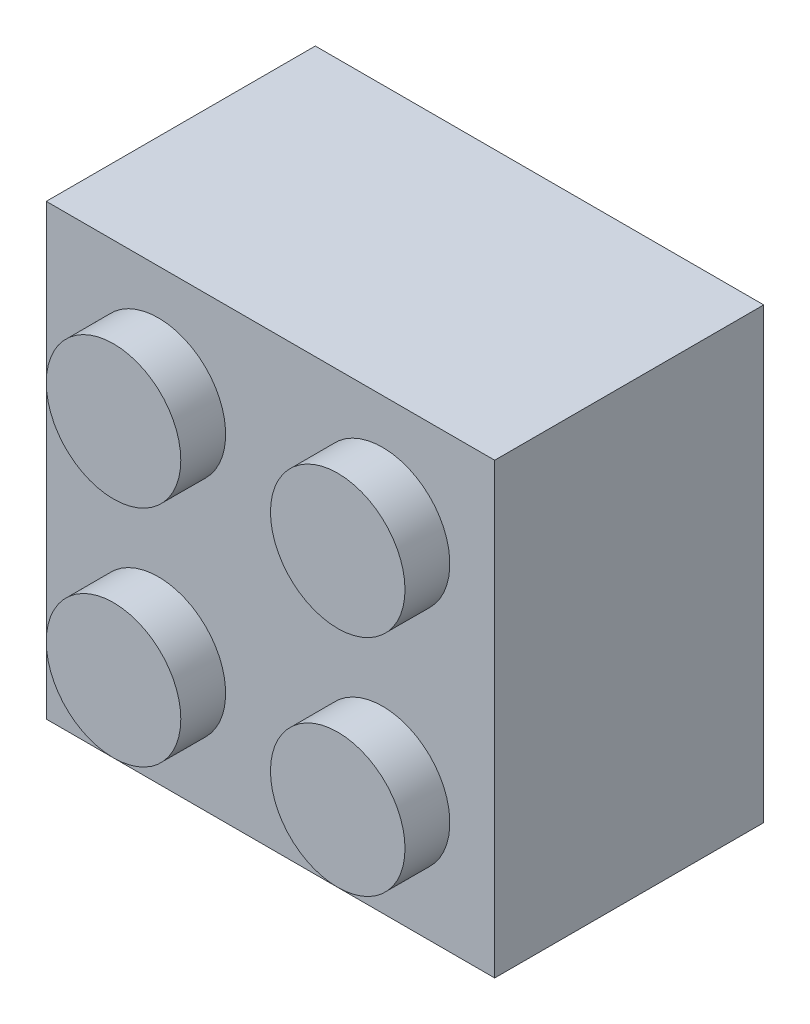
from build123d import *

# Parameters (mm, degrees)
SKETCH1_W            = 15.875
SKETCH1_H            = 15.875
BOSS_EXTRUDE1_DEPTH  = 9.525
SKETCH2_R            = 2.38125
BOSS_EXTRUDE2_DEPTH  = 1.5875
LPATTERN1_COUNT      = 2
LPATTERN1_PITCH      = 7.9375
LPATTERN1_COUNT_DIR2 = 2
LPATTERN1_PITCH_DIR2 = 7.9375
SHELL1_T             = -1.5875
SKETCH3_R            = 3.175
SKETCH3_R_2          = 2.38125
BOSS_EXTRUDE9_DEPTH  = 7.9375


with BuildPart() as part:
    # Sketch1 → Boss-Extrude1 (new body)
    with BuildSketch(Plane.XY):
        with Locations((7.9375, 7.9375)):
            Rectangle(SKETCH1_W, SKETCH1_H)
    extrude(amount=BOSS_EXTRUDE1_DEPTH)

    # Sketch2 → Boss-Extrude2 (add)
    with BuildSketch(Plane.XY.offset(9.525)):
        with Locations((3.96875, 11.90625)):
            Circle(SKETCH2_R)
    boss_extrude2 = extrude(amount=BOSS_EXTRUDE2_DEPTH)

    # LPattern1: Boss-Extrude2 2 × 2
    with Locations(*[(j * LPATTERN1_PITCH_DIR2, -i * LPATTERN1_PITCH, 0) for i in range(LPATTERN1_COUNT) for j in range(LPATTERN1_COUNT_DIR2) if (i, j) != (0, 0)]):
        add(boss_extrude2)

    # Shell1
    shell1_openings = [part.faces().sort_by_distance(p)[0] for p in [
        (7.9375, 7.9375, 0),
    ]]
    offset(amount=SHELL1_T, openings=shell1_openings, kind=Kind.INTERSECTION)

    # Sketch3 → Boss-Extrude9 (add)
    with BuildSketch(Plane(origin=(0, 0, 7.9375), x_dir=(-1, 0, 0), z_dir=(0, 0, -1))):
        with Locations((-7.9375, 7.9375)):
            Circle(SKETCH3_R)
        with Locations((-7.9375, 7.9375)):
            Circle(SKETCH3_R_2, mode=Mode.SUBTRACT)
    extrude(amount=BOSS_EXTRUDE9_DEPTH)


solid = part.part
